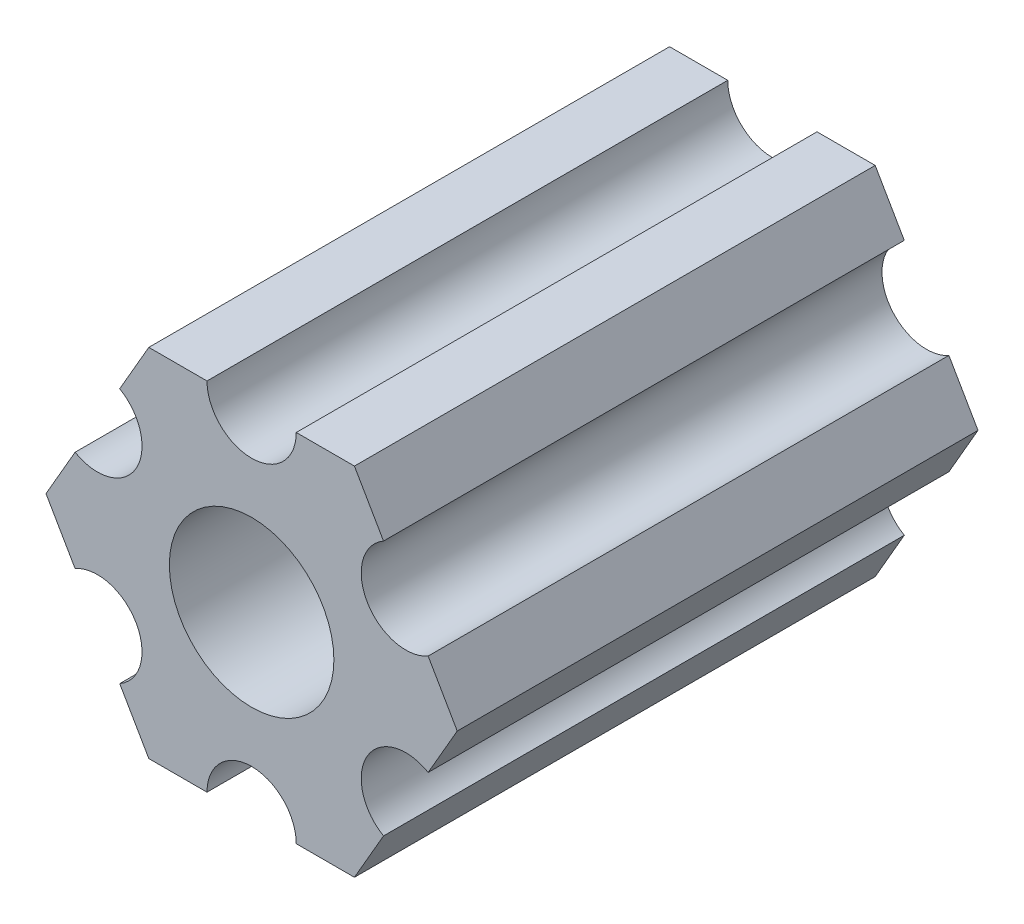
from build123d import *

# Parameters (mm, degrees)
SKETCH1_R           = 2.9337
BOSS_EXTRUDE1_DEPTH = 18.56994


with BuildPart() as part:
    # Sketch1 → Boss-Extrude1 (new body)
    with BuildSketch(Plane(origin=(0, 0, 0), x_dir=(-1, 0, 0), z_dir=(0, 0, -1))):
        with BuildLine():
            Line((-4.703606334, -4.55311485), (-3.666174209, -6.35))
            Line((-3.666174209, -6.35), (-1.591309959, -6.35))
            ThreePointArc((-1.591309959, -6.35), (0, -4.758690041), (1.591309959, -6.35))
            Line((1.591309959, -6.35), (3.666174209, -6.35))
            Line((3.666174209, -6.35), (4.703606334, -4.55311485))
            ThreePointArc((4.703606334, -4.55311485), (4.121146464, -2.37934502), (6.294916294, -1.79688515))
            Line((6.294916294, -1.79688515), (7.332348419, 0))
            Line((7.332348419, 0), (6.294916294, 1.79688515))
            ThreePointArc((6.294916294, 1.79688515), (4.121146464, 2.37934502), (4.703606334, 4.55311485))
            Line((4.703606334, 4.55311485), (3.666174209, 6.35))
            Line((3.666174209, 6.35), (1.591309959, 6.35))
            ThreePointArc((1.591309959, 6.35), (0, 4.758690041), (-1.591309959, 6.35))
            Line((-1.591309959, 6.35), (-3.666174209, 6.35))
            Line((-3.666174209, 6.35), (-4.703606334, 4.55311485))
            ThreePointArc((-4.703606334, 4.55311485), (-4.121146464, 2.37934502), (-6.294916294, 1.79688515))
            Line((-6.294916294, 1.79688515), (-7.332348419, 0))
            Line((-7.332348419, 0), (-6.294916294, -1.79688515))
            ThreePointArc((-6.294916294, -1.79688515), (-4.121146464, -2.37934502), (-4.703606334, -4.55311485))
        make_face()
        Circle(SKETCH1_R, mode=Mode.SUBTRACT)
    extrude(amount=-BOSS_EXTRUDE1_DEPTH)


solid = part.part
